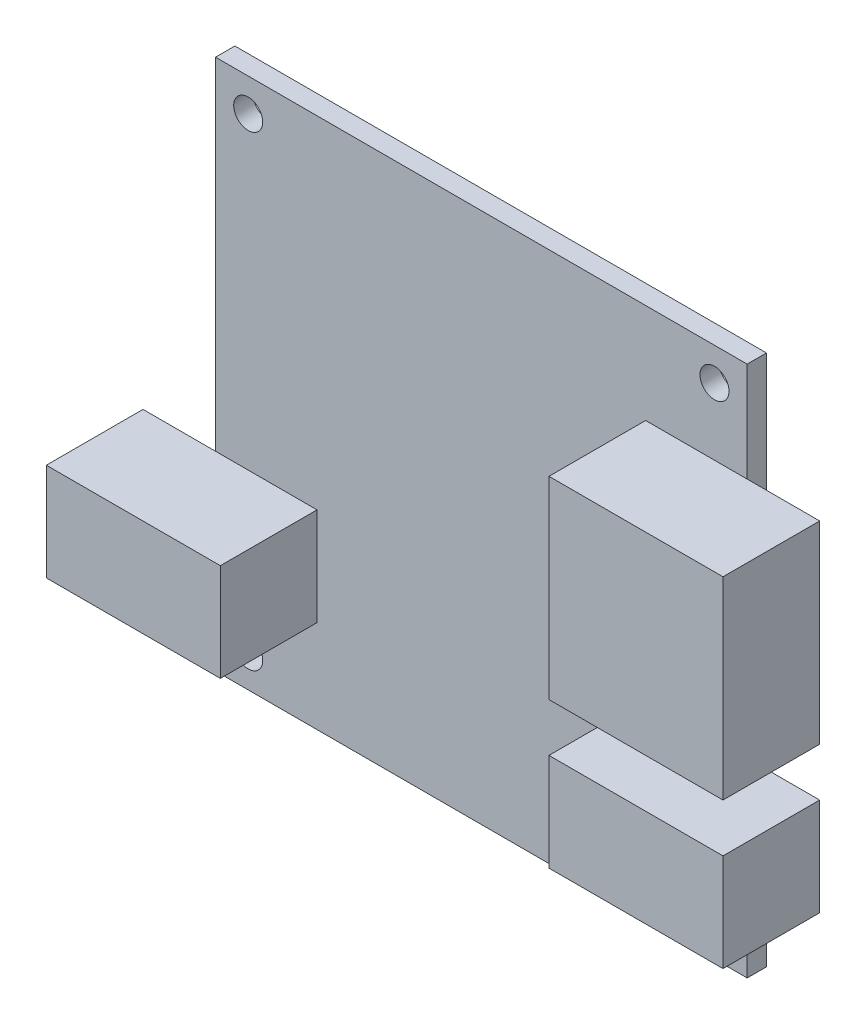
from build123d import *

# Parameters (mm, degrees)
SKETCH_2_W               = 54.99
SKETCH_2_H               = 54.99
EXTRUDE_1_DEPTH          = 2
SKETCH_3_R               = 1.5
CUT_EXTRUDE_1_DEPTH      = 39.935203223
MIRROR_2_COPY_1_SKETCH_R = 1.5
MIRROR_2_COPY_1_DEPTH    = 39.935203223
MIRROR_2_COPY_2_SKETCH_R = 1.5
MIRROR_2_COPY_2_DEPTH    = 39.935203223
SKETCH_4_W               = 18
SKETCH_4_H               = 20
EXTRUDE_2_DEPTH          = 10
SKETCH_5_W               = 18
SKETCH_5_H               = 10.1
EXTRUDE_3_DEPTH          = 10


with BuildPart() as part:
    # 草圖2 → 填料-伸長1 (new body)
    with BuildSketch(Plane.XY):
        Rectangle(SKETCH_2_W, SKETCH_2_H)
    extrude(amount=EXTRUDE_1_DEPTH)

    # 草圖3 → 除料-伸長1 (cut, through all)
    with BuildSketch(Plane.XY.offset(2)):
        with Locations((-24.115, -24.115)):
            Circle(SKETCH_3_R)
    cut_extrude_1 = extrude(amount=-CUT_EXTRUDE_1_DEPTH, mode=Mode.SUBTRACT)

    # 鏡射1: 除料-伸長1 across plane
    add(cut_extrude_1.mirror(Plane.ZX), mode=Mode.SUBTRACT)

    # 鏡射2 copy 1 sketch → 鏡射2 copy 1 (cut, through all)
    with BuildSketch(Plane(origin=(0, 0, 2), x_dir=(-1, 0, 0), z_dir=(0, 0, 1))):
        with Locations((-24.115, -24.115)):
            Circle(MIRROR_2_COPY_1_SKETCH_R)
    extrude(amount=-MIRROR_2_COPY_1_DEPTH, mode=Mode.SUBTRACT)

    # 鏡射2 copy 2 sketch → 鏡射2 copy 2 (cut, through all)
    with BuildSketch(Plane(origin=(0, 0, 2), x_dir=(-1, 0, 0), z_dir=(0, 0, 1))):
        with Locations((-24.115, 24.115)):
            Circle(MIRROR_2_COPY_2_SKETCH_R)
    extrude(amount=-MIRROR_2_COPY_2_DEPTH, mode=Mode.SUBTRACT)

    # 草圖4 → 填料-伸長2 (add)
    with BuildSketch(Plane.XY.offset(2)):
        with Locations((25.995, 7.195)):
            Rectangle(SKETCH_4_W, SKETCH_4_H)
    extrude(amount=EXTRUDE_2_DEPTH)

    # 草圖5 → 填料-伸長3 (add)
    with BuildSketch(Plane.XY.offset(2)):
        with Locations((25.995, -12.855)):
            Rectangle(SKETCH_5_W, SKETCH_5_H)
    extrude_3 = extrude(amount=EXTRUDE_3_DEPTH)

    # 鏡射3: 填料-伸長3 across plane
    add(extrude_3.mirror(Plane(origin=(0, 0, 0), x_dir=(0, 0, 1), z_dir=(1, 0, 0))))


solid = part.part
